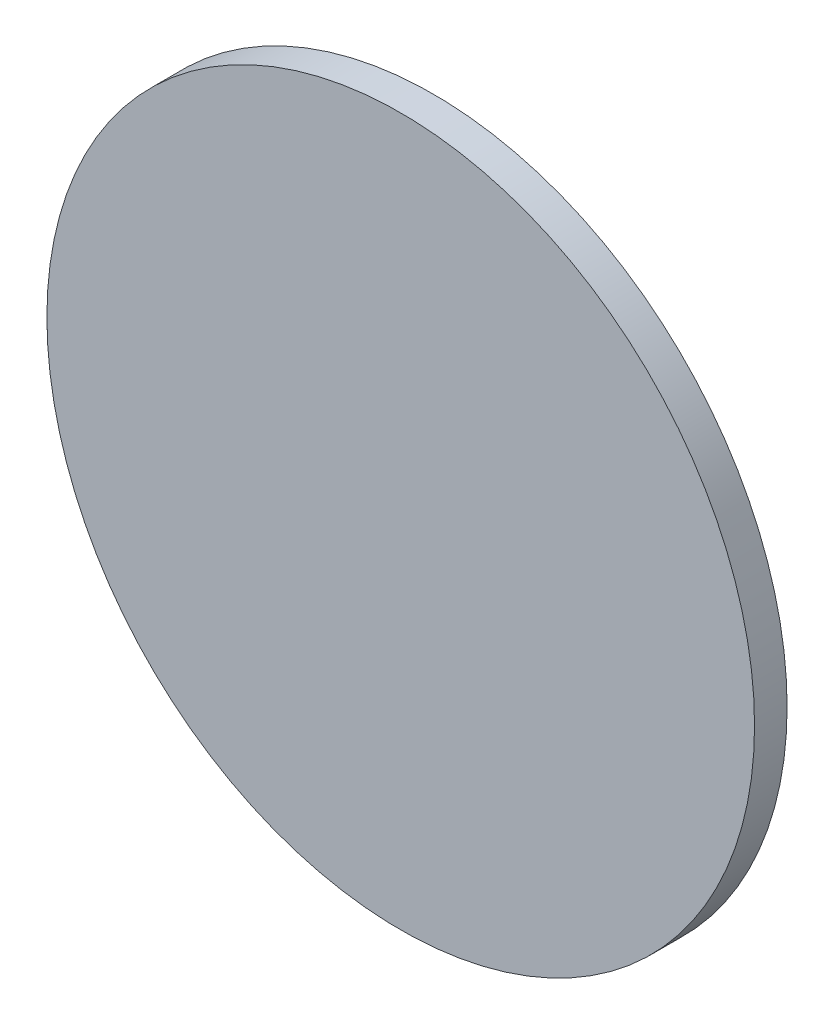
from build123d import *

# Parameters (mm, degrees)
SKETCH_1_R      = 25
EXTRUDE_1_DEPTH = 2.3


with BuildPart() as part:
    # 草图1 → 凸台-拉伸1 (new body)
    with BuildSketch(Plane.XY):
        with Locations((217.229967885, 123.126483669)):
            Circle(SKETCH_1_R)
    extrude(amount=EXTRUDE_1_DEPTH)


solid = part.part
